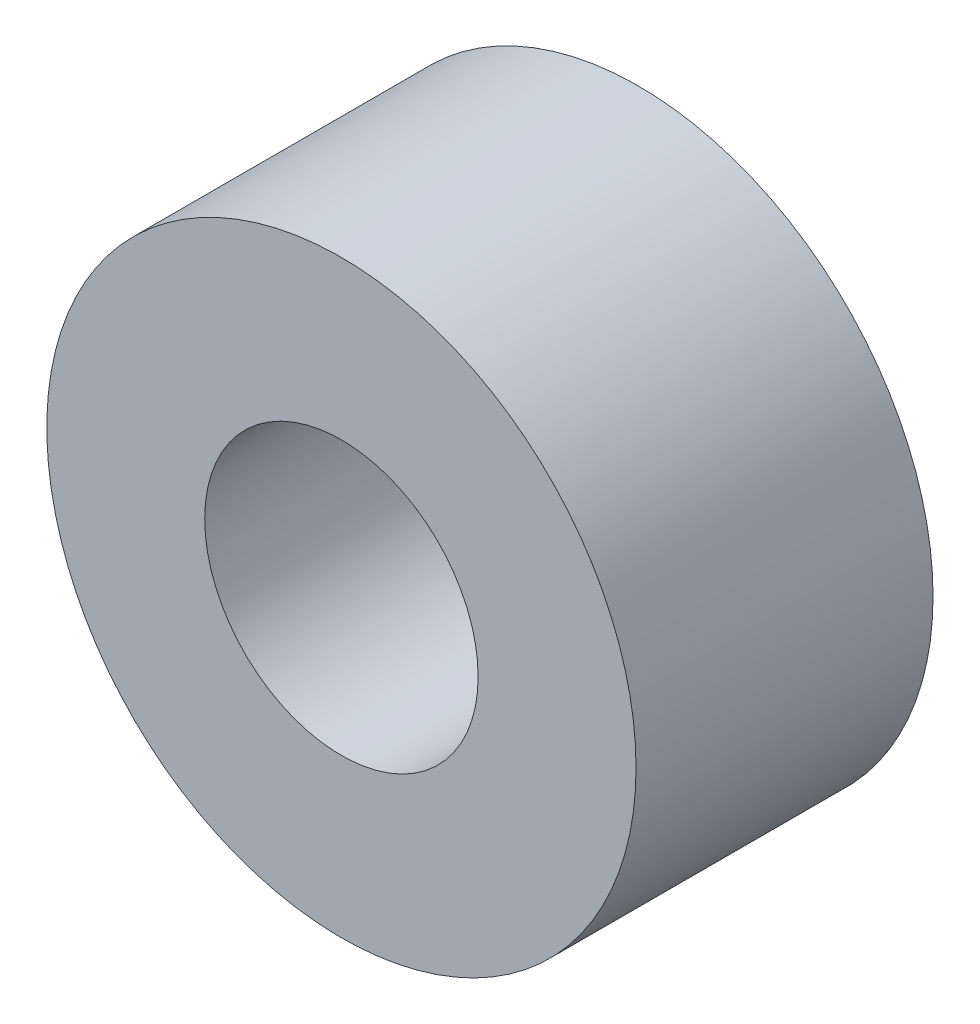
from build123d import *

# Parameters (mm, degrees)
SKETCH1_R           = 3.175
SKETCH1_R_2         = 1.4732
BOSS_EXTRUDE1_DEPTH = 3.2004


with BuildPart() as part:
    # Sketch1 → Boss-Extrude1 (new body)
    with BuildSketch(Plane.XY):
        Circle(SKETCH1_R)
        Circle(SKETCH1_R_2, mode=Mode.SUBTRACT)
    extrude(amount=BOSS_EXTRUDE1_DEPTH)


solid = part.part
